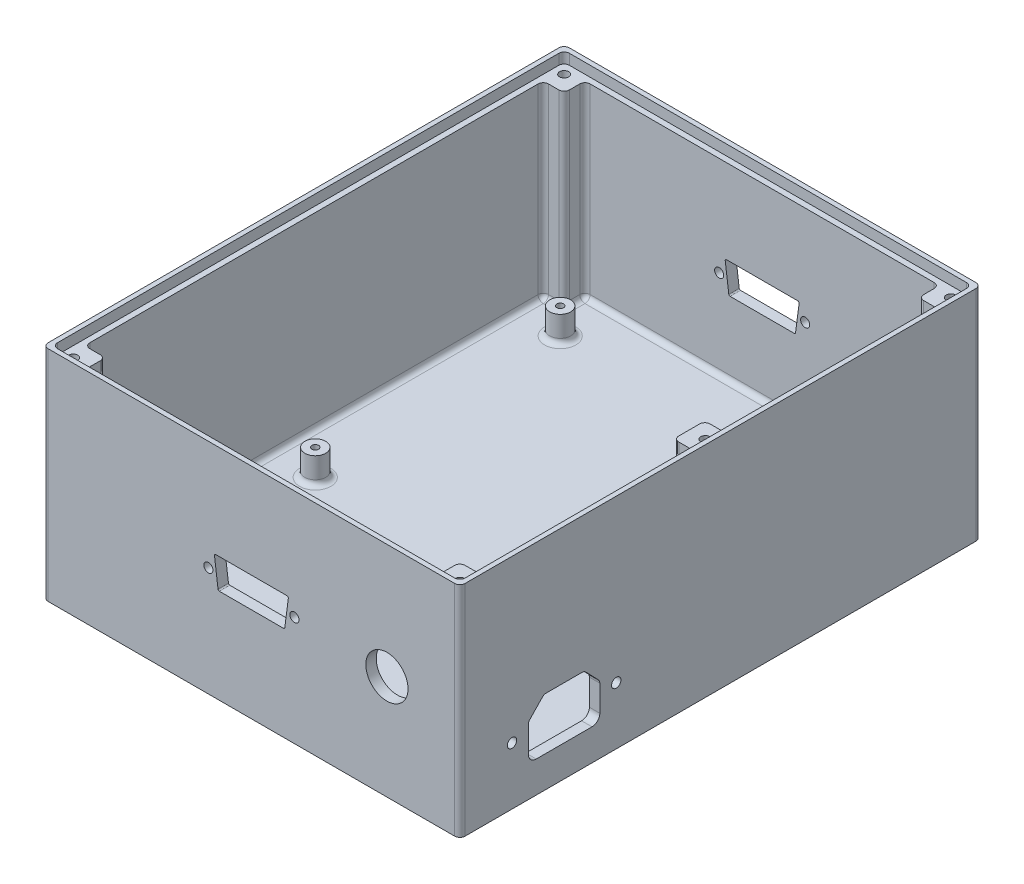
from build123d import *

# Parameters (mm, degrees)
ESBO_O1_W                = 200
ESBO_O1_H                = 84
RESSALTO_EXTRUS_O1_DEPTH = 80
ESBO_O4_R                = 1.75
CORTE_EXTRUS_O1_DEPTH    = 76
FILETE1_R                = 2
ESBO_O7_R                = 1.75
CORTE_EXTRUS_O2_DEPTH    = 100
FILETE3_R                = 0.5
ESBO_O8_R                = 8.1
CORTE_EXTRUS_O3_DEPTH    = 4
ESBO_O9_R                = 4
ESBO_O9_R_2              = 1.3
ESBO_O9_R_3              = 1.75
RESSALTO_EXTRUS_O2_DEPTH = 10
ESBO_O11_R               = 1.8
CORTE_EXTRUS_O4_DEPTH    = 4
FILETE4_R                = 2
FILETE5_R                = 2
FILETE7_R                = 2
ESBO_O17_W               = 156.4
ESBO_O17_H               = 196.4
CORTE_EXTRUS_O8_DEPTH    = 4
FILETE10_R               = 2


with BuildPart() as part:
    # Esboço1 → Ressalto-extrusão1 (new body, symmetric)
    with BuildSketch(Plane(origin=(0, 0, 0), x_dir=(0, 0, -1), z_dir=(1, 0, 0))):
        with Locations((0, 42)):
            Rectangle(ESBO_O1_W, ESBO_O1_H)
    extrude(amount=RESSALTO_EXTRUS_O1_DEPTH, both=True)

    # Esboço4 → Corte-extrusão1 (cut)
    with BuildSketch(Plane(origin=(0, 84, 0), x_dir=(1, 0, 0), z_dir=(0, 1, 0))):
        with Locations((-74.2, -94.2)):
            Circle(ESBO_O4_R)
        with Locations((-74.2, 94.2)):
            Circle(ESBO_O4_R)
        with Locations((74.2, -94.2)):
            Circle(ESBO_O4_R)
        with Locations((74.2, 94.2)):
            Circle(ESBO_O4_R)
        with Locations((74.2, 0)):
            Circle(ESBO_O4_R)
        Polygon((-68, -96), (68, -96), (68, -88), (76, -88), (76, -6), (68, -6), (68, 6), (76, 6), (76, 88), (68, 88), (68, 96), (-68, 96), (-68, 88), (-76, 88), (-76, -88), (-68, -88), align=None)
    extrude(amount=-CORTE_EXTRUS_O1_DEPTH, mode=Mode.SUBTRACT)

    # Filete1
    filete1_edges = [part.edges().sort_by_distance(p)[0] for p in [
        (80, 42, -100),
        (68, 46, 88),
        (-68, 46, 88),
        (-68, 46, -88),
        (68, 46, -88),
        (68, 46, -6),
        (68, 46, 6),
        (-80, 42, -100),
        (-80, 42, 100),
        (80, 42, 100),
    ]]
    fillet(filete1_edges, radius=FILETE1_R)

    # Esboço7 → Corte-extrusão2 (cut, symmetric)
    with BuildSketch(Plane.XY):
        with Locations((-16.5, 42)):
            Circle(ESBO_O7_R)
        with Locations((16.5, 42)):
            Circle(ESBO_O7_R)
        Polygon((-12.75, 36.25), (12.75, 36.25), (14.25, 47.75), (-14.25, 47.75), align=None)
    extrude(amount=CORTE_EXTRUS_O2_DEPTH, both=True, mode=Mode.SUBTRACT)

    # Filete3
    filete3_edges = [part.edges().sort_by_distance(p)[0] for p in [
        (14.25, 47.75, 98),
        (14.25, 47.75, -98),
        (12.75, 36.25, 98),
        (12.75, 36.25, -98),
        (-12.75, 36.25, 98),
        (-12.75, 36.25, -98),
        (-14.25, 47.75, 98),
        (-14.25, 47.75, -98),
    ]]
    fillet(filete3_edges, radius=FILETE3_R)

    # Esboço8 → Corte-extrusão3 (cut)
    with BuildSketch(Plane(origin=(0, 0, 100), x_dir=(-1, 0, 0), z_dir=(0, 0, -1))):
        with Locations((-52, 40)):
            Circle(ESBO_O8_R)
    extrude(amount=CORTE_EXTRUS_O3_DEPTH, mode=Mode.SUBTRACT)

    # Esboço9 → Ressalto-extrusão2 (add)
    with BuildSketch(Plane(origin=(0, 8, 0), x_dir=(1, 0, 0), z_dir=(0, 1, 0))):
        with Locations((-60, 78.5)):
            Circle(ESBO_O9_R)
        with Locations((-60, 78.5)):
            Circle(ESBO_O9_R_2, mode=Mode.SUBTRACT)
        with Locations((60, 78.5)):
            Circle(ESBO_O9_R)
        with Locations((60, 78.5)):
            Circle(ESBO_O9_R_2, mode=Mode.SUBTRACT)
        with Locations((60, -15.5)):
            Circle(ESBO_O9_R)
        with Locations((60, -15.5)):
            Circle(ESBO_O9_R_2, mode=Mode.SUBTRACT)
        with Locations((-60, -15.5)):
            Circle(ESBO_O9_R)
        with Locations((-60, -15.5)):
            Circle(ESBO_O9_R_2, mode=Mode.SUBTRACT)
        with Locations((-46, -86)):
            Circle(ESBO_O9_R)
        with Locations((-46, -86)):
            Circle(ESBO_O9_R_3, mode=Mode.SUBTRACT)
        with Locations((0, -86)):
            Circle(ESBO_O9_R)
        with Locations((0, -86)):
            Circle(ESBO_O9_R_3, mode=Mode.SUBTRACT)
    extrude(amount=RESSALTO_EXTRUS_O2_DEPTH)

    # Esboço11 → Corte-extrusão4 (cut)
    with BuildSketch(Plane(origin=(80, 0, 0), x_dir=(0, 0, -1), z_dir=(1, 0, 0))):
        with Locations((-80, 22)):
            Circle(ESBO_O11_R)
        with Locations((-40, 22)):
            Circle(ESBO_O11_R)
        with BuildLine():
            Line((-73.7, 15), (-73.7, 25.790784626))
            Line((-73.7, 25.790784626), (-67.749735767, 32))
            Line((-67.749735767, 32), (-52.250264233, 32))
            Line((-52.250264233, 32), (-46.3, 25.790784626))
            Line((-46.3, 25.790784626), (-46.3, 15))
            ThreePointArc((-46.3, 15), (-47.178679656, 12.878679656), (-49.3, 12))
            Line((-49.3, 12), (-70.7, 12))
            ThreePointArc((-70.7, 12), (-72.821320344, 12.878679656), (-73.7, 15))
        make_face()
    extrude(amount=-CORTE_EXTRUS_O4_DEPTH, mode=Mode.SUBTRACT)

    # Filete4
    filete4_edges = [part.edges().sort_by_distance(p)[0] for p in [
        (76, 46, 88),
        (68, 46, 96),
        (-68, 46, 96),
        (-76, 46, 88),
        (-76, 46, -88),
        (-68, 46, -96),
        (68, 46, -96),
        (76, 46, -88),
        (76, 46, -6),
        (76, 46, 6),
    ]]
    fillet(filete4_edges, radius=FILETE4_R)

    # Filete5
    filete5_edges = [part.edges().sort_by_distance(p)[0] for p in [
        (72, 8, -6),
        (72, 8, 88),
        (-68.585786438, 8, 88.585786438),
        (-68.585786438, 8, -88.585786438),
        (68.585786438, 8, -88.585786438),
        (68.585786438, 8, 5.414213562),
        (68.585786438, 8, -5.414213562),
        (68.585786438, 8, 88.585786438),
        (56, 8, -78.5),
        (56, 8, 15.5),
        (-64, 8, 15.5),
        (-4, 8, 86),
        (-50, 8, 86),
        (-64, 8, -78.5),
        (76, 8, -47),
        (68, 8, 92),
        (76, 8, 47),
        (72, 8, 6),
        (72, 8, -88),
        (0, 8, -96),
        (-68, 8, -92),
        (-76, 8, 0),
        (-72, 8, 88),
        (0, 8, 96),
        (75.414213562, 8, 87.414213562),
        (67.414213562, 8, 95.414213562),
        (-67.414213562, 8, 95.414213562),
        (-75.414213562, 8, 87.414213562),
        (-67.414213562, 8, -95.414213562),
        (-75.414213562, 8, -87.414213562),
        (75.414213562, 8, -87.414213562),
        (67.414213562, 8, -95.414213562),
        (75.414213562, 8, 6.585786438),
        (75.414213562, 8, -6.585786438),
        (-68, 8, 92),
        (-72, 8, -88),
        (68, 8, -92),
        (68, 8, 0),
    ]]
    fillet(filete5_edges, radius=FILETE5_R)

    # Filete7
    filete7_edges = [part.edges().sort_by_distance(p)[0] for p in [
        (78, 25.790784626, 73.7),
        (78, 32, 67.749735767),
        (78, 32, 52.250264233),
        (78, 25.790784626, 46.3),
    ]]
    fillet(filete7_edges, radius=FILETE7_R)

    # Esboço17 → Corte-extrusão8 (cut)
    with BuildSketch(Plane(origin=(0, 84, 0), x_dir=(1, 0, 0), z_dir=(0, 1, 0))):
        Rectangle(ESBO_O17_W, ESBO_O17_H)
    extrude(amount=-CORTE_EXTRUS_O8_DEPTH, mode=Mode.SUBTRACT)

    # Filete10
    filete10_edges = [part.edges().sort_by_distance(p)[0] for p in [
        (-78.2, 82, -98.2),
        (78.2, 82, -98.2),
        (78.2, 82, 98.2),
        (-78.2, 82, 98.2),
    ]]
    fillet(filete10_edges, radius=FILETE10_R)


solid = part.part
